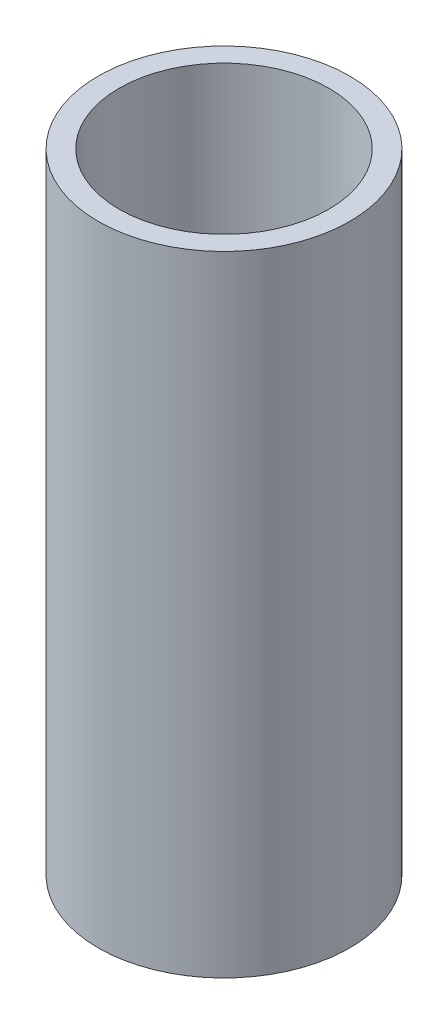
from build123d import *

# Parameters (mm, degrees)
CROQUIS1_R              = 3
CROQUIS1_R_2            = 2.5
SALIENTE_EXTRUIR1_DEPTH = 15


with BuildPart() as part:
    # Croquis1 → Saliente-Extruir1 (new body)
    with BuildSketch(Plane(origin=(0, 0, 0), x_dir=(1, 0, 0), z_dir=(0, 1, 0))):
        Circle(CROQUIS1_R)
        Circle(CROQUIS1_R_2, mode=Mode.SUBTRACT)
    extrude(amount=SALIENTE_EXTRUIR1_DEPTH)


solid = part.part
